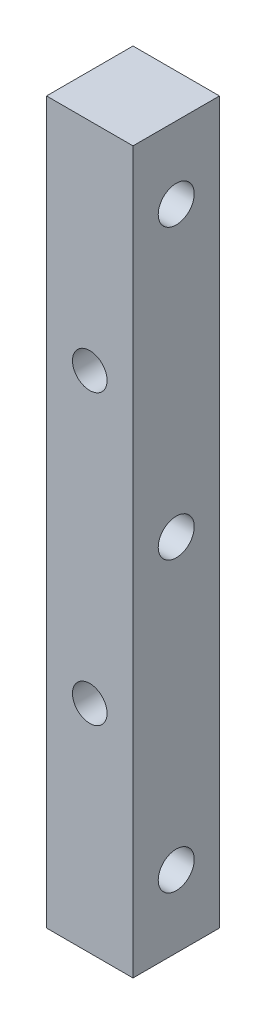
from build123d import *

# Parameters (mm, degrees)
SKETCH_1_W          = 6
SKETCH_1_H          = 70
EXTRUDE_1_DEPTH     = 6
SKETCH_4_R          = 1.25
CUT_EXTRUDE_3_DEPTH = 8
SKETCH_6_R          = 1.2
CUT_EXTRUDE_5_DEPTH = 10
SKETCH_7_W          = 6
SKETCH_7_H          = 6
CUT_EXTRUDE_6_DEPTH = 20


with BuildPart() as part:
    # 草图1 → 凸台-拉伸1 (new body)
    with BuildSketch(Plane.XY):
        with Locations((3, 35)):
            Rectangle(SKETCH_1_W, SKETCH_1_H)
    extrude(amount=EXTRUDE_1_DEPTH)

    # 草图4 → 切除-拉伸3 (cut)
    with BuildSketch(Plane.ZY):
        with Locations((3, 65)):
            Circle(SKETCH_4_R)
        with Locations((3, 45)):
            Circle(SKETCH_4_R)
        with Locations((3, 25)):
            Circle(SKETCH_4_R)
        with Locations((3, 5)):
            Circle(SKETCH_4_R)
    extrude(amount=-CUT_EXTRUDE_3_DEPTH, mode=Mode.SUBTRACT)

    # 草图6 → 切除-拉伸5 (cut)
    with BuildSketch(Plane.XY.offset(6)):
        with Locations((3, 15)):
            Circle(SKETCH_6_R)
        with Locations((3, 35)):
            Circle(SKETCH_6_R)
        with Locations((3, 55)):
            Circle(SKETCH_6_R)
    extrude(amount=-CUT_EXTRUDE_5_DEPTH, mode=Mode.SUBTRACT)

    # 草图7 → 切除-拉伸6 (cut)
    with BuildSketch(Plane(origin=(0, 70, 0), x_dir=(1, 0, 0), z_dir=(0, 1, 0))):
        with Locations((3, -3)):
            Rectangle(SKETCH_7_W, SKETCH_7_H)
    extrude(amount=-CUT_EXTRUDE_6_DEPTH, mode=Mode.SUBTRACT)


solid = part.part
